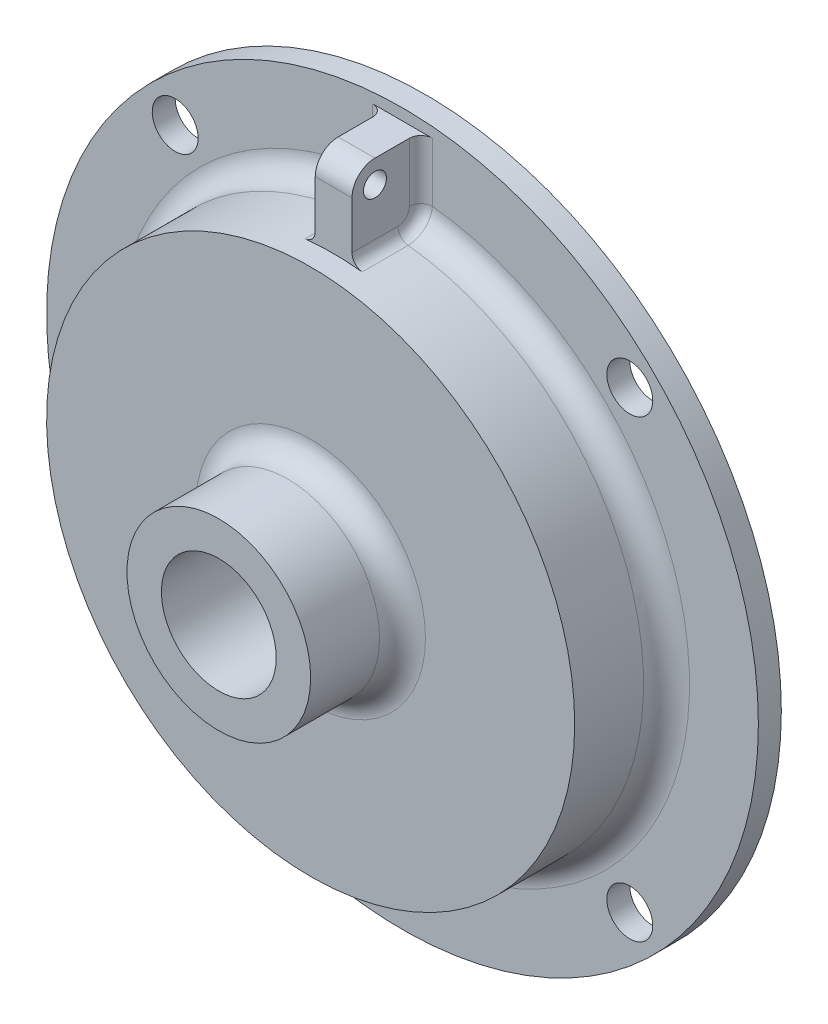
from build123d import *

# Parameters (mm, degrees)
SKETCH1_R           = 49.2125
BASE_EXTRUDE_DEPTH  = 3.175
SKETCH5_R           = 3.175
CUT_EXTRUDE2_DEPTH  = 4.175
CIRPATTERN1_COUNT   = 4
SKETCH2_R           = 36.5125
BOSS_EXTRUDE1_DEPTH = 12.7
SKETCH3_R           = 12.7
BOSS_EXTRUDE2_DEPTH = 12.7
FILLET1_R           = 3.175
SKETCH6_W           = 5.08
SKETCH6_H           = 9.525
BOSS_EXTRUDE3_DEPTH = 47.625
SKETCH4_R           = 7.9375
CUT_EXTRUDE1_DEPTH  = 29.575
FILLET2_R           = 3.175
CUT_EXTRUDE3_REACH  = 53.752
SKETCH7_R           = 1.5875
FILLET3_R           = 1.5875


with BuildPart() as part:
    # Sketch1 → Base-Extrude (new body)
    with BuildSketch(Plane.XY):
        Circle(SKETCH1_R)
    extrude(amount=BASE_EXTRUDE_DEPTH)

    # Sketch5 → Cut-Extrude2 (cut, through all)
    with BuildSketch(Plane.XY.offset(3.175)):
        with Locations((31.430896424, 31.430896424)):
            Circle(SKETCH5_R)
    cut_extrude2 = extrude(amount=-CUT_EXTRUDE2_DEPTH, mode=Mode.SUBTRACT)

    # CirPattern1: Cut-Extrude2 ×4 about axis
    cirpattern1_axis = Axis((0, 0, 0), (0, 0, 1))
    for i in range(1, CIRPATTERN1_COUNT):
        add(cut_extrude2.rotate(cirpattern1_axis, i * 360 / CIRPATTERN1_COUNT), mode=Mode.SUBTRACT)

    # Sketch2 → Boss-Extrude1 (add)
    with BuildSketch(Plane.XY.offset(3.175)):
        Circle(SKETCH2_R)
    extrude(amount=BOSS_EXTRUDE1_DEPTH)

    # Sketch3 → Boss-Extrude2 (add)
    with BuildSketch(Plane.XY.offset(15.875)):
        Circle(SKETCH3_R)
    extrude(amount=BOSS_EXTRUDE2_DEPTH)

    # Fillet1
    fillet1_edges = [part.edges().sort_by_distance(p)[0] for p in [
        (-36.5125, 0, 3.175),
        (-12.7, 0, 15.875),
    ]]
    fillet(fillet1_edges, radius=FILLET1_R)

    # Sketch6 → Boss-Extrude3 (add)
    with BuildSketch(Plane(origin=(0, 0, 0), x_dir=(1, 0, 0), z_dir=(0, 1, 0))):
        with Locations((0, -7.9375)):
            Rectangle(SKETCH6_W, SKETCH6_H)
    extrude(amount=BOSS_EXTRUDE3_DEPTH)

    # Sketch4 → Cut-Extrude1 (cut, through all)
    with BuildSketch(Plane.XY.offset(28.575)):
        Circle(SKETCH4_R)
    extrude(amount=-CUT_EXTRUDE1_DEPTH, mode=Mode.SUBTRACT)

    # Fillet2
    fillet2_edges = [part.edges().sort_by_distance(p)[0] for p in [
        (0, 47.625, 12.7),
    ]]
    fillet(fillet2_edges, radius=FILLET2_R)

    # Sketch7 → Cut-Extrude3 (cut, up to next)
    with BuildSketch(Plane(origin=(2.54, 0, 0), x_dir=(0, 0, -1), z_dir=(1, 0, 0)), mode=Mode.PRIVATE) as cut_extrude3_sk1:
        with Locations((-9.525, 44.45)):
            Circle(SKETCH7_R)
    cut_extrude3_tool1 = extrude(cut_extrude3_sk1.sketch, amount=-CUT_EXTRUDE3_REACH, mode=Mode.PRIVATE) & part.part
    add(cut_extrude3_tool1.solids().sort_by_distance((2.54, 44.45, 9.525))[0], mode=Mode.SUBTRACT)

    # Fillet3
    fillet3_edges = [part.edges().sort_by_distance(p)[0] for p in [
        (-2.54, 36.424045029, 9.5249997),
        (-2.54, 43.615568299, 3.175),
        (2.54, 43.615568299, 3.175),
        (2.54, 36.424045029, 9.5249997),
    ]]
    fillet(fillet3_edges, radius=FILLET3_R)


solid = part.part
